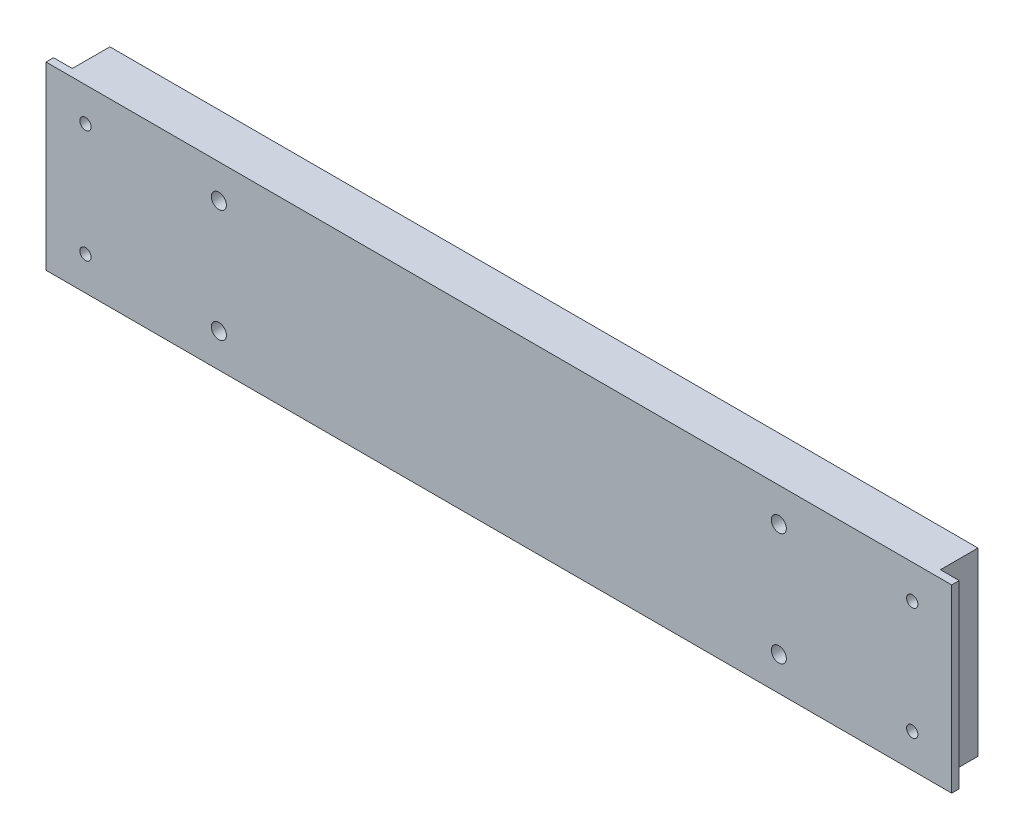
from build123d import *

# Parameters (mm, degrees)
ESQUISSE1_W      = 241
ESQUISSE1_H      = 48
ESQUISSE1_R      = 1.5
ESQUISSE1_R_2    = 2
EXTRUSION1_DEPTH = 12
ESQUISSE2_W      = 5
ESQUISSE2_H      = 10
EXTRUSION2_DEPTH = 49


with BuildPart() as part:
    # Esquisse1 → Extrusion1 (new body)
    with BuildSketch(Plane.XY):
        with Locations((120.5, -24)):
            Rectangle(ESQUISSE1_W, ESQUISSE1_H)
        with Locations((230.5, -39)):
            Circle(ESQUISSE1_R, mode=Mode.SUBTRACT)
        with Locations((10.5, -9)):
            Circle(ESQUISSE1_R, mode=Mode.SUBTRACT)
        with Locations((10.5, -39)):
            Circle(ESQUISSE1_R, mode=Mode.SUBTRACT)
        with Locations((230.5, -9)):
            Circle(ESQUISSE1_R, mode=Mode.SUBTRACT)
        with Locations((195, -39)):
            Circle(ESQUISSE1_R_2, mode=Mode.SUBTRACT)
        with Locations((46, -9)):
            Circle(ESQUISSE1_R_2, mode=Mode.SUBTRACT)
        with Locations((46, -39)):
            Circle(ESQUISSE1_R_2, mode=Mode.SUBTRACT)
        with Locations((195, -9)):
            Circle(ESQUISSE1_R_2, mode=Mode.SUBTRACT)
    extrude(amount=EXTRUSION1_DEPTH)

    # Esquisse2 → Extrusion2 (cut, through all)
    with BuildSketch(Plane(origin=(0, 0, 0), x_dir=(1, 0, 0), z_dir=(0, 1, 0))):
        with Locations((2.5, -5)):
            Rectangle(ESQUISSE2_W, ESQUISSE2_H)
        with Locations((238.5, -5)):
            Rectangle(ESQUISSE2_W, ESQUISSE2_H)
    extrude(amount=-EXTRUSION2_DEPTH, mode=Mode.SUBTRACT)


solid = part.part
